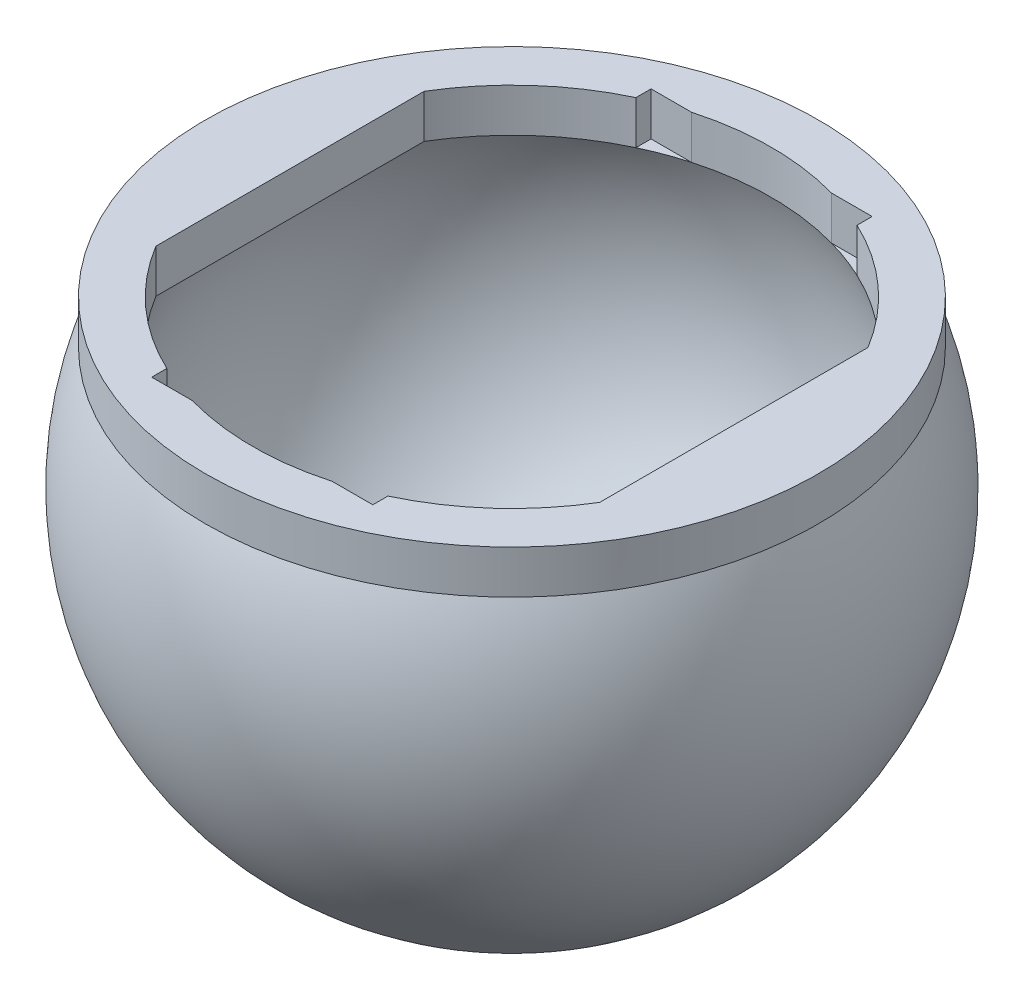
from build123d import *

# Parameters (mm, degrees)
BOSS_EXTRUDE1_DEPTH = 2.5
CUT_EXTRUDE1_DEPTH  = 2.5


with BuildPart() as part:
    # Sketch1 one side → Revolve2 (revolve)
    with BuildSketch(Plane.XY):
        with BuildLine():
            ThreePointArc((0, -16.5), (-13.923900316, -8.852965605), (-14.941552797, 7))
            Line((-14.941552797, 7), (-17.663521733, 7))
            ThreePointArc((-17.663521733, 7), (-15.716233646, -10.677078252), (0, -19))
            Line((0, -19), (0, -16.5))
        make_face()
    revolve(axis=Axis((0, -16.5, 0), (0, 1, 0)))

    # Sketch2 → Boss-Extrude1 (add)
    with BuildSketch(Plane(origin=(0, 7, 0), x_dir=(1, 0, 0), z_dir=(0, 1, 0))):
        with BuildLine():
            ThreePointArc((17.663521733, 0), (16.399068955, 6.562814748), (12.786743696, 12.186024194))
            Line((12.786743696, 12.186024194), (12.786743696, 7.729759741))
            ThreePointArc((12.786743696, 7.729759741), (14.392772597, 4.012243385), (14.941552797, 0))
            ThreePointArc((14.941552797, 0), (14.392772597, -4.012243385), (12.786743696, -7.729759741))
            Line((12.786743696, -7.729759741), (12.786743696, -12.186024194))
            ThreePointArc((12.786743696, -12.186024194), (16.399068955, -6.562814748), (17.663521733, 0))
        make_face()
        with BuildLine():
            ThreePointArc((14.941552797, 0), (14.392772597, 4.012243385), (12.786743696, 7.729759741))
            Line((12.786743696, 7.729759741), (12.786743696, -7.729759741))
            ThreePointArc((12.786743696, -7.729759741), (14.392772597, -4.012243385), (14.941552797, 0))
        make_face()
        with BuildLine():
            Line((-12.786743696, 7.729759741), (-12.786743696, 12.186024194))
            ThreePointArc((-12.786743696, 12.186024194), (-17.663521733, 0), (-12.786743696, -12.186024194))
            Line((-12.786743696, -12.186024194), (-12.786743696, -7.729759741))
            ThreePointArc((-12.786743696, -7.729759741), (-14.941552797, 0), (-12.786743696, 7.729759741))
        make_face()
        with BuildLine():
            Line((-12.786743696, -7.729759741), (-12.786743696, 7.729759741))
            ThreePointArc((-12.786743696, 7.729759741), (-14.941552797, 0), (-12.786743696, -7.729759741))
        make_face()
        with BuildLine():
            Line((8.645855328, 12.186024194), (12.786743696, 12.186024194))
            ThreePointArc((12.786743696, 12.186024194), (0, 17.663521733), (-12.786743696, 12.186024194))
            Line((-12.786743696, 12.186024194), (-8.645855328, 12.186024194))
            ThreePointArc((-8.645855328, 12.186024194), (0, 14.941552797), (8.645855328, 12.186024194))
        make_face()
        with BuildLine():
            Line((12.786743696, 7.729759741), (12.786743696, 12.186024194))
            Line((12.786743696, 12.186024194), (8.645855328, 12.186024194))
            ThreePointArc((8.645855328, 12.186024194), (10.9454853, 10.170857955), (12.786743696, 7.729759741))
        make_face()
        with BuildLine():
            Line((-8.645855328, 12.186024194), (-12.786743696, 12.186024194))
            Line((-12.786743696, 12.186024194), (-12.786743696, 7.729759741))
            ThreePointArc((-12.786743696, 7.729759741), (-10.9454853, 10.170857955), (-8.645855328, 12.186024194))
        make_face()
        with BuildLine():
            Line((-12.786743696, -7.729759741), (-12.786743696, -12.186024194))
            Line((-12.786743696, -12.186024194), (-8.645855328, -12.186024194))
            ThreePointArc((-8.645855328, -12.186024194), (-10.9454853, -10.170857955), (-12.786743696, -7.729759741))
        make_face()
        with BuildLine():
            Line((12.786743696, -12.186024194), (12.786743696, -7.729759741))
            ThreePointArc((12.786743696, -7.729759741), (10.9454853, -10.170857955), (8.645855328, -12.186024194))
            Line((8.645855328, -12.186024194), (12.786743696, -12.186024194))
        make_face()
        with BuildLine():
            ThreePointArc((-12.786743696, -12.186024194), (0, -17.663521733), (12.786743696, -12.186024194))
            Line((12.786743696, -12.186024194), (8.645855328, -12.186024194))
            ThreePointArc((8.645855328, -12.186024194), (0, -14.941552797), (-8.645855328, -12.186024194))
            Line((-8.645855328, -12.186024194), (-12.786743696, -12.186024194))
        make_face()
    extrude(amount=BOSS_EXTRUDE1_DEPTH)

    # Sketch3 → Cut-Extrude1 (cut)
    with BuildSketch(Plane(origin=(0, 9.5, 0), x_dir=(1, 0, 0), z_dir=(0, 1, 0))):
        with BuildLine():
            Line((-6.37, 14.38749457), (-6.37, 13.515661286))
            ThreePointArc((-6.37, 13.515661286), (-5.218801949, 14.000503784), (-4.031128874, 14.38749457))
            Line((-4.031128874, 14.38749457), (-6.37, 14.38749457))
        make_face()
        with BuildLine():
            Line((6.37, 14.38749457), (4.031128874, 14.38749457))
            ThreePointArc((4.031128874, 14.38749457), (5.218801949, 14.000503784), (6.37, 13.515661286))
            Line((6.37, 13.515661286), (6.37, 14.38749457))
        make_face()
        with BuildLine():
            ThreePointArc((6.37, -13.515661286), (5.218801949, -14.000503784), (4.031128874, -14.38749457))
            Line((4.031128874, -14.38749457), (6.37, -14.38749457))
            Line((6.37, -14.38749457), (6.37, -13.515661286))
        make_face()
        with BuildLine():
            Line((-6.37, -13.515661286), (-6.37, -14.38749457))
            Line((-6.37, -14.38749457), (-4.031128874, -14.38749457))
            ThreePointArc((-4.031128874, -14.38749457), (-5.218801949, -14.000503784), (-6.37, -13.515661286))
        make_face()
    extrude(amount=-CUT_EXTRUDE1_DEPTH, mode=Mode.SUBTRACT)


solid = part.part
